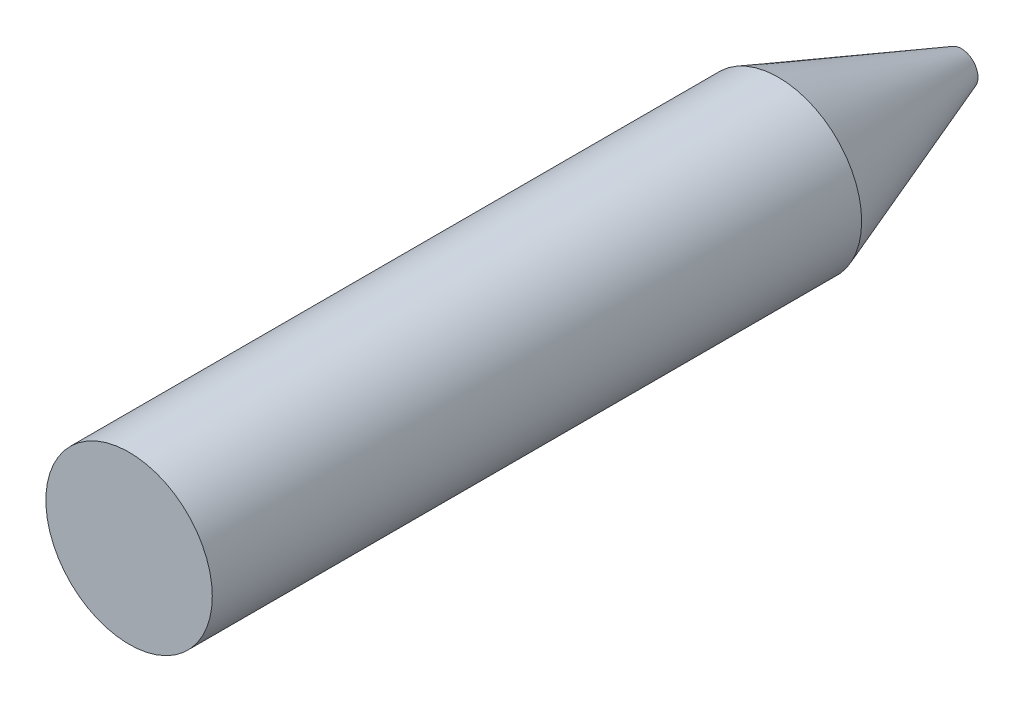
from build123d import *


with BuildPart() as part:
    # Sketch1 → Revolve1 (revolve)
    with BuildSketch(Plane(origin=(0, 0, 0), x_dir=(1, 0, 0), z_dir=(0, 1, 0))):
        Polygon((0, 0), (10, 0), (10, 78.020180644), (2, 100), (0, 100), align=None)
    revolve(axis=Axis((0, 0, 68.693168404), (0, 0, -1)))


solid = part.part
